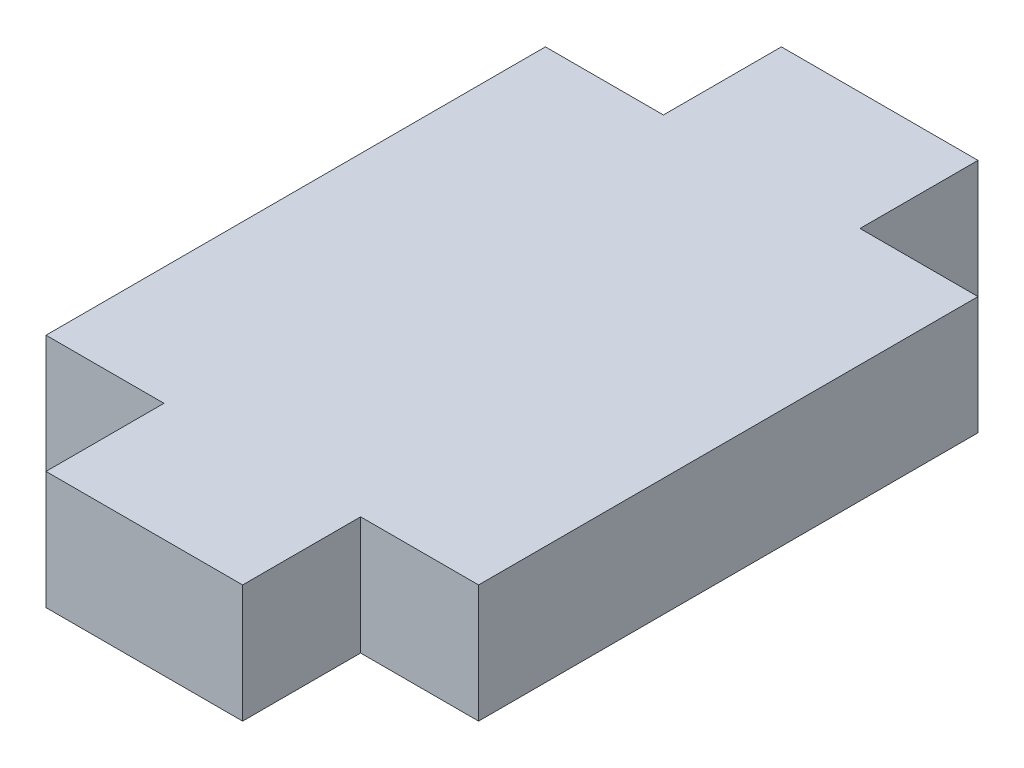
from build123d import *

# Parameters (mm, degrees)
BOSS_EXTRUDE1_DEPTH = 1.5


with BuildPart() as part:
    # Sketch1 → Boss-Extrude1 (new body, symmetric)
    with BuildSketch(Plane(origin=(0, 0, 0), x_dir=(1, 0, 0), z_dir=(0, 1, 0))):
        Polygon((-5.5, 6.35), (-5.5, -6.35), (-2.5, -6.35), (-2.5, -9.35), (2.5, -9.35), (2.5, -6.35), (5.5, -6.35), (5.5, 6.35), (2.5, 6.35), (2.5, 9.35), (-2.5, 9.35), (-2.5, 6.35), align=None)
    extrude(amount=BOSS_EXTRUDE1_DEPTH, both=True)


solid = part.part
